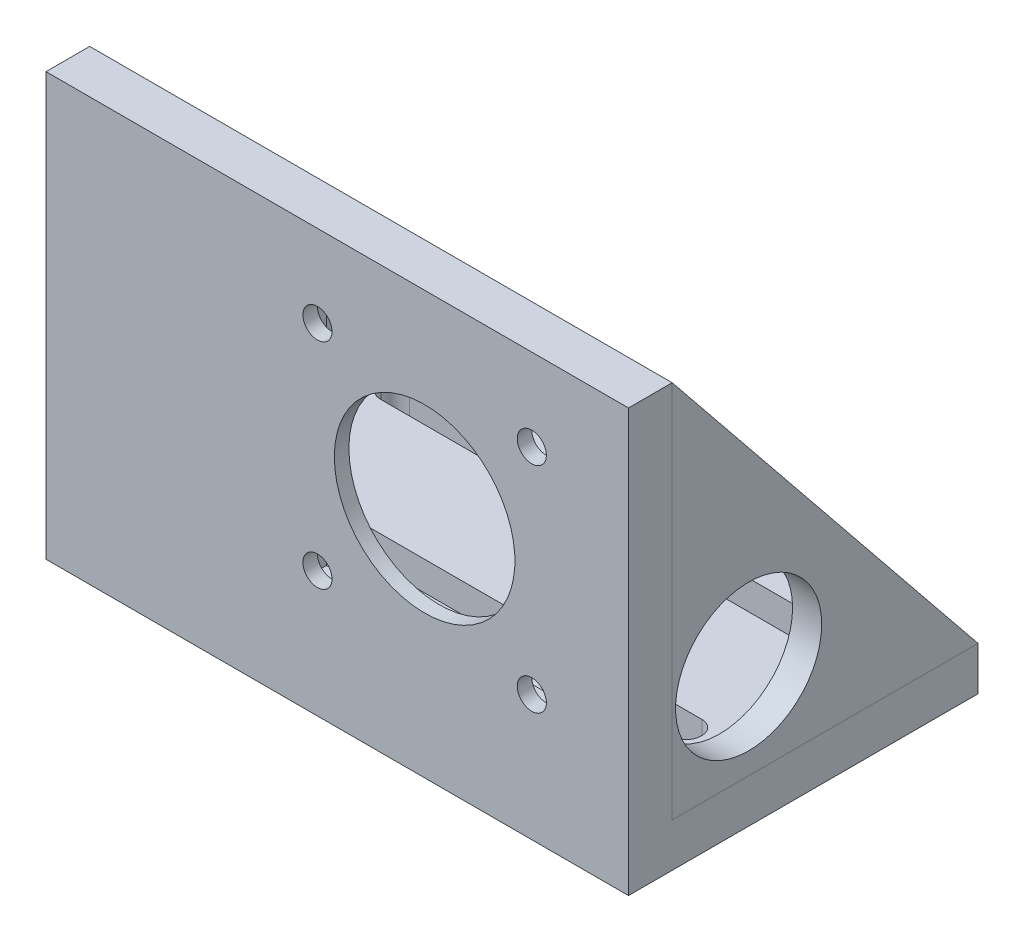
from build123d import *

# Parameters (mm, degrees)
SKETCH2_W               = 127
SKETCH2_H               = 76.2
BOSS_EXTRUDE1_DEPTH     = 9.525
SKETCH3_W               = 127
SKETCH3_H               = 9.525
BOSS_EXTRUDE2_DEPTH     = 82.55
BOSS_EXTRUDE3_DEPTH     = 6.35
BOSS_EXTRUDE4_DEPTH     = 6.35
SKETCH7_R               = 19.685
SKETCH7_R_2             = 3.175
CUT_EXTRUDE1_DEPTH      = 10.525
SKETCH11_W              = 61.921486798
SKETCH11_H              = 61.884587426
CUT_EXTRUDE4_DEPTH      = 6.35
CUT_EXTRUDE5_DEPTH      = 93.075
SKETCH13_R              = 15.929247536
CUT_EXTRUDE6_DEPTH      = 121.65
CUT_EXTRUDE6_DEPTH_BACK = 7.35


with BuildPart() as part:
    # Sketch2 → Boss-Extrude1 (new body)
    with BuildSketch(Plane(origin=(0, 0, 0), x_dir=(1, 0, 0), z_dir=(0, 1, 0))):
        with Locations((63.5, 38.1)):
            Rectangle(SKETCH2_W, SKETCH2_H)
    extrude(amount=BOSS_EXTRUDE1_DEPTH)

    # Sketch3 → Boss-Extrude2 (add)
    with BuildSketch(Plane(origin=(0, 9.525, 0), x_dir=(1, 0, 0), z_dir=(0, 1, 0))):
        with Locations((63.5, 4.7625)):
            Rectangle(SKETCH3_W, SKETCH3_H)
    extrude(amount=BOSS_EXTRUDE2_DEPTH)

    # Sketch5 → Boss-Extrude4 (add)
    with BuildSketch(Plane.ZY):
        Polygon((-9.525, 92.075), (-76.2, 9.525), (-9.525, 9.525), align=None)
    extrude(amount=-BOSS_EXTRUDE4_DEPTH)

    # Sketch7 → Cut-Extrude1 (cut, through all)
    with BuildSketch(Plane(origin=(0, 0, -9.525), x_dir=(-1, 0, 0), z_dir=(0, 0, -1))):
        with Locations((-82.55, 50.8)):
            Circle(SKETCH7_R)
        with Locations((-105.918, 74.168)):
            Circle(SKETCH7_R_2)
        with Locations((-59.182, 74.168)):
            Circle(SKETCH7_R_2)
        with Locations((-59.182, 27.432)):
            Circle(SKETCH7_R_2)
        with Locations((-105.918, 27.432)):
            Circle(SKETCH7_R_2)
    extrude(amount=-CUT_EXTRUDE1_DEPTH, mode=Mode.SUBTRACT)

    # Sketch11 → Cut-Extrude4 (cut)
    with BuildSketch(Plane(origin=(0, 0, -9.525), x_dir=(-1, 0, 0), z_dir=(0, 0, -1))):
        with Locations((-82.55, 50.8)):
            Rectangle(SKETCH11_W, SKETCH11_H)
    extrude(amount=-CUT_EXTRUDE4_DEPTH, mode=Mode.SUBTRACT)

    # Sketch12 → Cut-Extrude5 (cut, through all)
    with BuildSketch(Plane.XZ):
        with BuildLine():
            Line((15.748, -63.5), (111.252, -63.5))
            ThreePointArc((111.252, -63.5), (113.407261469, -62.607261469), (114.3, -60.452))
            Line((114.3, -60.452), (114.3, -60.198))
            ThreePointArc((114.3, -60.198), (113.407261469, -58.042738531), (111.252, -57.15))
            Line((111.252, -57.15), (15.748, -57.15))
            ThreePointArc((15.748, -57.15), (13.592738531, -58.042738531), (12.7, -60.198))
            Line((12.7, -60.198), (12.7, -60.452))
            ThreePointArc((12.7, -60.452), (13.592738531, -62.607261469), (15.748, -63.5))
        make_face()
        with BuildLine():
            Line((15.748, -25.4), (111.252, -25.4))
            ThreePointArc((111.252, -25.4), (113.407261469, -26.292738531), (114.3, -28.448))
            Line((114.3, -28.448), (114.3, -28.702))
            ThreePointArc((114.3, -28.702), (113.407261469, -30.857261469), (111.252, -31.75))
            Line((111.252, -31.75), (15.748, -31.75))
            ThreePointArc((15.748, -31.75), (13.592738531, -30.857261469), (12.7, -28.702))
            Line((12.7, -28.702), (12.7, -28.448))
            ThreePointArc((12.7, -28.448), (13.592738531, -26.292738531), (15.748, -25.4))
        make_face()
    extrude(amount=-CUT_EXTRUDE5_DEPTH, mode=Mode.SUBTRACT)


with BuildPart() as body_2:
    # Sketch4 → Boss-Extrude3 (new body)
    with BuildSketch(Plane(origin=(127, 0, 0), x_dir=(0, 0, -1), z_dir=(1, 0, 0))):
        Polygon((9.525, 92.075), (76.2, 9.525), (9.525, 9.525), align=None)
    extrude(amount=-BOSS_EXTRUDE3_DEPTH)


with BuildPart() as cut_extrude6_tool:
    # Sketch13 → Cut-Extrude6 (new body, two sides)
    with BuildSketch(Plane(origin=(6.35, 0, 0), x_dir=(0, 0, -1), z_dir=(1, 0, 0))) as cut_extrude6_sk:
        with Locations((26.19375, 30.1625)):
            Circle(SKETCH13_R)
    extrude(amount=CUT_EXTRUDE6_DEPTH)
    extrude(cut_extrude6_sk.sketch, amount=-CUT_EXTRUDE6_DEPTH_BACK)


with BuildPart() as part_1:
    add(part.part)

    # Cut-Extrude6: cut by cut_extrude6_tool
    add(cut_extrude6_tool.part, mode=Mode.SUBTRACT)


with BuildPart() as body_2_1:
    add(body_2.part)

    # Cut-Extrude6: cut by cut_extrude6_tool
    add(cut_extrude6_tool.part, mode=Mode.SUBTRACT)


solid = Compound([part_1.part, body_2_1.part])
